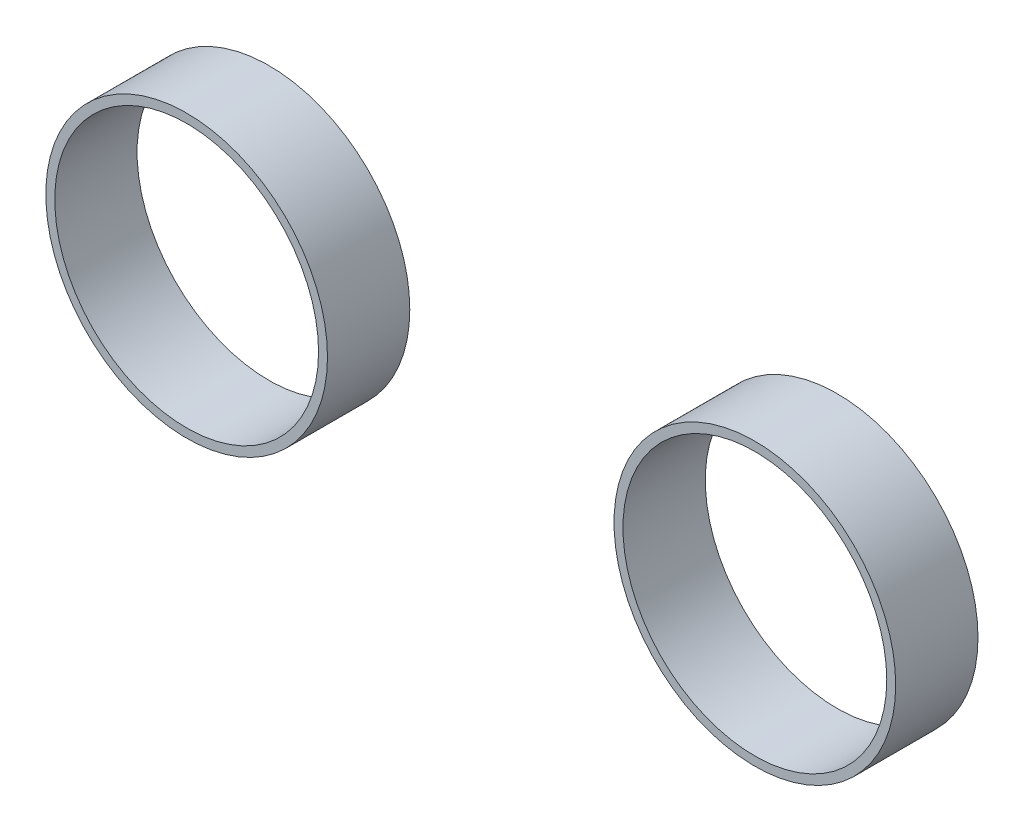
from build123d import *

# Parameters (mm, degrees)
SKETCH1_R             = 69.4
SKETCH1_R_2           = 65
BOSS_EXTRUDE1_DEPTH   = 40.56
BOSS_EXTRUDE1_2_DEPTH = 40.56


with BuildPart() as part:
    # Sketch1 → Boss-Extrude1 (new body)
    with BuildSketch(Plane.XY):
        with Locations((1715.980472759, -423.382336202)):
            Circle(SKETCH1_R)
        with Locations((1715.980472759, -423.382336202)):
            Circle(SKETCH1_R_2, mode=Mode.SUBTRACT)
    extrude(amount=BOSS_EXTRUDE1_DEPTH)


with BuildPart() as body_2:
    # Sketch1 → Boss-Extrude1 2 (new body)
    with BuildSketch(Plane.XY):
        with Locations((1435.980472759, -423.382336202)):
            Circle(SKETCH1_R)
        with Locations((1435.980472759, -423.382336202)):
            Circle(SKETCH1_R_2, mode=Mode.SUBTRACT)
    extrude(amount=BOSS_EXTRUDE1_2_DEPTH)


solid = Compound([part.part, body_2.part])
